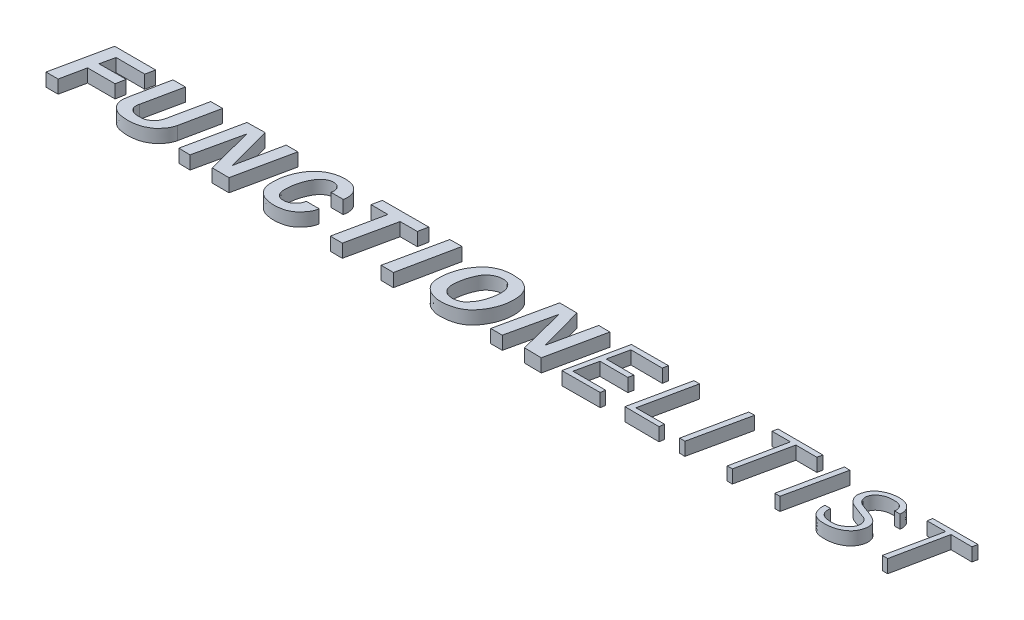
from build123d import *

# Parameters (mm, degrees)
BOSS_EXTRUDE1_DEPTH    = 25.4
BOSS_EXTRUDE1_2_DEPTH  = 25.4
BOSS_EXTRUDE1_3_DEPTH  = 25.4
BOSS_EXTRUDE1_4_DEPTH  = 25.4
BOSS_EXTRUDE1_5_DEPTH  = 25.4
BOSS_EXTRUDE1_6_DEPTH  = 25.4
BOSS_EXTRUDE1_7_DEPTH  = 25.4
BOSS_EXTRUDE1_8_DEPTH  = 25.4
BOSS_EXTRUDE1_9_DEPTH  = 25.4
BOSS_EXTRUDE1_10_DEPTH = 25.4
BOSS_EXTRUDE1_11_DEPTH = 25.4
BOSS_EXTRUDE1_12_DEPTH = 25.4
BOSS_EXTRUDE1_13_DEPTH = 25.4
BOSS_EXTRUDE1_14_DEPTH = 25.4
BOSS_EXTRUDE1_15_DEPTH = 25.4


with BuildPart() as part:
    # Sketch2 → Boss-Extrude1 (new body)
    with BuildSketch(Plane(origin=(0, 0, 0), x_dir=(1, 0, 0), z_dir=(0, 1, 0))):
        with BuildLine():
            add(Edge.make_bspline(
                [(1094.427173213, 172.997146135), (1091.367551701, 172.906654033), (1085.158357781, 172.889487077), (1076.817502855, 175.50371822), (1068.345517925, 178.404168185), (1061.504603762, 184.040645414), (1054.691032721, 192.448499642), (1052.102551889, 202.272409533), (1052.016567477, 212.151169643), (1052.188561023, 219.614340802), (1053.848126401, 228.614644219), (1056.261017051, 238.892210234), (1061.524966489, 251.84212287), (1068.453103531, 262.32447772), (1076.878332495, 272.415104771), (1085.877906637, 279.006460855), (1097.47703413, 284.33681498), (1108.098800253, 286.704500027), (1118.910320823, 287.395086765), (1128.310390006, 286.483917691), (1137.402240239, 285.679117248), (1144.816033322, 281.623384425), (1153.026267593, 275.767906793), (1158.262775228, 266.157317215), (1160.627021608, 255.642523502), (1161.153569292, 246.53633637), (1160.608373851, 237.02784107), (1158.723980019, 227.131158299), (1155.939995019, 218.091844341), (1151.872712965, 208.995350554), (1145.861238908, 198.526470413), (1137.37183718, 188.258938379), (1127.672033786, 181.13652136), (1119.963990562, 177.706508815), (1112.131167595, 175.264500154), (1103.861910343, 173.448851684), (1097.481943993, 173.087494771), (1094.427173213, 172.997146135)],
                knots=[0, 0, 0, 0, 0.025729682, 0.051931851, 0.073305152, 0.100820113, 0.125326139, 0.163809491, 0.183248995, 0.208899637, 0.226567481, 0.260387765, 0.297881818, 0.343867956, 0.365822433, 0.408624519, 0.436521725, 0.473173661, 0.49973853, 0.527560869, 0.553081825, 0.575613369, 0.59785567, 0.637572301, 0.663955073, 0.688711586, 0.714252853, 0.744180522, 0.773515788, 0.793866448, 0.828165547, 0.875213576, 0.905069137, 0.928882672, 0.946053606, 0.97431111, 1, 1, 1, 1], degree=3))
        make_face()
        with BuildLine():
            add(Edge.make_bspline(
                [(1098.369477116, 189.410559153), (1095.339913898, 189.726806675), (1089.506155554, 190.429641806), (1083.417050133, 193.896903849), (1080.724632289, 197.743942709), (1078.071870765, 201.356194307), (1076.633917417, 207.003621776), (1075.897203299, 214.974381959), (1077.513403819, 224.232305335), (1079.080110954, 234.174301375), (1082.37947845, 243.466317785), (1086.27753448, 252.729872997), (1092.195532664, 261.57819181), (1100.08218752, 266.558304181), (1107.922996096, 270.026920408), (1116.188907666, 270.926869451), (1125.301619767, 269.806230986), (1131.392204102, 264.299131948), (1135.086077048, 258.700627105), (1137.001086768, 252.391282942), (1137.069034285, 244.812539886), (1136.750024768, 235.251639968), (1133.98689045, 223.98986243), (1130.367111642, 213.1486423), (1124.624773393, 203.404718722), (1118.399178317, 196.717256904), (1113.593721508, 192.548947207), (1111.578933122, 191.848802187)],
                knots=[0, 0, 0, 0, 0.047623639, 0.07606652, 0.096690248, 0.113170499, 0.138968172, 0.177316361, 0.22569027, 0.270714363, 0.319285709, 0.364188653, 0.412774027, 0.466537936, 0.493207323, 0.533134683, 0.583074459, 0.616438865, 0.645306629, 0.677257278, 0.707725549, 0.751889888, 0.811960352, 0.870512297, 0.912744055, 0.970141319, 1, 1, 1, 1], degree=3))
            add(Edge.make_bspline(
                [(1098.369477116, 189.410559153), (1099.77902503, 189.263420439), (1105.610683136, 190.072330898), (1109.513215015, 191.130958937), (1111.578933122, 191.848802187)],
                knots=[0, 0, 0, 0, 0.517018761, 1, 1, 1, 1], degree=3))
        make_face(mode=Mode.SUBTRACT)
    extrude(amount=BOSS_EXTRUDE1_DEPTH)


with BuildPart() as body_2:
    # Sketch2 → Boss-Extrude1 2 (new body)
    with BuildSketch(Plane(origin=(0, 0, 0), x_dir=(1, 0, 0), z_dir=(0, 1, 0))):
        Polygon((330.211143627, 175.588495452), (353.316026943, 284.791417581), (432.439856311, 284.656163172), (428.787987263, 267.208344389), (373.46893391, 267.343598798), (367.517739906, 240.427971372), (419.590687439, 240.563225781), (416.344581619, 222.574389361), (363.324853222, 222.574389361), (353.557861827, 175.622714777), align=None)
    extrude(amount=BOSS_EXTRUDE1_2_DEPTH)


with BuildPart() as body_3:
    # Sketch2 → Boss-Extrude1 3 (new body)
    with BuildSketch(Plane(origin=(0, 0, 0), x_dir=(1, 0, 0), z_dir=(0, 1, 0))):
        with BuildLine():
            Line((465.540196151, 284.777155902), (450.797700158, 211.908410215))
            add(Edge.make_bspline(
                [(450.797700158, 211.908410215), (450.401697608, 209.951061263), (449.717545439, 204.157501389), (449.852392166, 197.959453274), (452.916704033, 189.162058328), (457.105550768, 184.239524107), (463.310862511, 178.887230238), (471.371299141, 175.382283828), (480.944030166, 174.219947151), (490.741843397, 173.364325457), (501.427717175, 174.468473393), (510.969600186, 176.46316405), (519.088167565, 180.128268969), (524.38190265, 183.416430797), (529.852703333, 186.567368504), (533.682775693, 191.213583721), (537.986958283, 195.989246419), (541.830788276, 201.489509829), (544.333106096, 207.38196973), (545.625201628, 211.201711691), (545.952916561, 212.778062002)],
                knots=[0, 0, 0, 0, 0.043908318, 0.110716089, 0.159392641, 0.219822207, 0.270449273, 0.330054706, 0.407839802, 0.477214937, 0.542146355, 0.63916272, 0.686233556, 0.733611926, 0.774060684, 0.821314961, 0.862079378, 0.913354099, 0.965139079, 1, 1, 1, 1], degree=3))
            Line((545.952916561, 212.778062002), (560.973854285, 285.030673838))
            Line((560.973854285, 285.030673838), (538.156978731, 284.984513081))
            Line((538.156978731, 284.984513081), (523.059522937, 212.98850838))
            add(Edge.make_bspline(
                [(474.104814663, 212.245925239), (473.820102179, 210.898651301), (473.341939715, 208.239660277), (473.391161168, 204.320719503), (473.872328244, 200.272471918), (476.172637579, 196.820507521), (479.426327198, 193.909333014), (483.996464702, 191.420527044), (490.181454969, 190.681063656), (497.056461391, 190.888433007), (503.5345067, 191.282569508), (508.939863463, 193.838388348), (513.258359653, 196.459428642), (516.953418015, 200.170161375), (519.81744566, 204.139227183), (521.924654749, 208.586712246), (522.742802557, 211.47814781), (523.059522937, 212.98850838)],
                knots=[0, 0, 0, 0, 0.055066425, 0.106590232, 0.156186474, 0.214690168, 0.266458337, 0.329688368, 0.418336241, 0.509803742, 0.605349791, 0.672337188, 0.745494903, 0.805585857, 0.879409694, 0.939580838, 1, 1, 1, 1], degree=3))
            Line((474.104814663, 212.245925239), (489.465951386, 284.935604612))
            Line((489.465951386, 284.935604612), (465.540196151, 284.777155902))
        make_face()
    extrude(amount=BOSS_EXTRUDE1_3_DEPTH)


with BuildPart() as body_4:
    # Sketch2 → Boss-Extrude1 4 (new body)
    with BuildSketch(Plane(origin=(0, 0, 0), x_dir=(1, 0, 0), z_dir=(0, 1, 0))):
        Polygon((585.218028048, 176.630460577), (607.888615981, 285.05501156), (642.387336748, 285.712130051), (665.715043172, 199.629607755), (683.457242424, 285.05501156), (705.943017035, 285.05501156), (682.635555628, 175.606991878), (650.172327201, 175.832430964), (626.952101312, 265.782626398), (607.113461717, 176.05787005), align=None)
    extrude(amount=BOSS_EXTRUDE1_4_DEPTH)


with BuildPart() as body_5:
    # Sketch2 → Boss-Extrude1 5 (new body)
    with BuildSketch(Plane(origin=(0, 0, 0), x_dir=(1, 0, 0), z_dir=(0, 1, 0))):
        with BuildLine():
            Line((796.528941351, 210.628773166), (821.363078455, 210.546812318))
            add(Edge.make_bspline(
                [(821.363078455, 210.546812318), (820.77586806, 205.084344469), (817.839684571, 198.332262823), (811.655602268, 190.447639529), (807.21814937, 185.342420577), (800.284432967, 180.05995394), (792.975181558, 176.082230005), (782.817673814, 174.009032956), (773.328021779, 172.58882257), (763.090067393, 173.529854994), (754.815944969, 175.210852365), (747.039980307, 178.257494428), (740.837431201, 183.420592228), (735.750465053, 189.811616705), (732.077539355, 199.629262376), (731.647655755, 212.18724466), (732.829275604, 225.694382033), (735.676598698, 236.095343852), (738.851822107, 245.197553714), (742.366016671, 252.237485189), (747.373116337, 260.721814049), (753.597255082, 267.548587626), (763.319959007, 276.65282138), (777.323695952, 283.194769785), (794.296815946, 286.298936908), (808.067949658, 284.769811956), (816.894555728, 281.225334283), (821.796806378, 276.928067532), (825.579463184, 272.689102131), (828.534772144, 267.303026755), (830.251032957, 259.4855433), (830.146607452, 253.307878925), (829.039741043, 249.395709479)],
                knots=[0, 0, 0, 0, 0.054999379, 0.072083259, 0.101177463, 0.122849587, 0.159869316, 0.183760308, 0.22711176, 0.256099158, 0.286962557, 0.312224743, 0.339401935, 0.367390346, 0.393755775, 0.443631789, 0.492575935, 0.530284588, 0.552055401, 0.589796325, 0.609451943, 0.651288915, 0.682398817, 0.743437002, 0.803855527, 0.854688806, 0.881272097, 0.898176147, 0.919988387, 0.938384456, 0.959446239, 1, 1, 1, 1], degree=3))
            Line((829.039741043, 249.395709479), (805.332899039, 249.395709479))
            add(Edge.make_bspline(
                [(796.528941351, 210.628773166), (796.136286957, 207.143896896), (794.317143157, 202.515966143), (789.847204333, 197.386058571), (786.193317877, 193.63919518), (780.215976284, 190.897113654), (773.273623453, 189.83302603), (765.80104898, 190.617660036), (760.06637365, 195.035277001), (756.050037195, 202.065995616), (755.978368859, 212.837420057), (757.032167583, 225.019535529), (760.349440305, 238.597129076), (765.052947191, 249.372676122), (770.597538656, 258.154387459), (776.40475905, 263.78689348), (783.241032826, 267.680480164), (789.985496621, 269.17248683), (795.619296807, 268.370210579), (800.023473378, 266.901536893), (805.762336688, 261.270620556), (806.796474701, 254.337681856), (805.332899039, 249.395709479)],
                knots=[0, 0, 0, 0, 0.063236051, 0.086131848, 0.122713905, 0.156521304, 0.202500897, 0.248775137, 0.287135484, 0.328458086, 0.390432241, 0.476348248, 0.550172603, 0.641096201, 0.687260725, 0.736691832, 0.785332173, 0.827671212, 0.858232345, 0.887348473, 0.90946641, 1, 1, 1, 1], degree=3))
        make_face()
    extrude(amount=BOSS_EXTRUDE1_5_DEPTH)


with BuildPart() as body_6:
    # Sketch2 → Boss-Extrude1 6 (new body)
    with BuildSketch(Plane(origin=(0, 0, 0), x_dir=(1, 0, 0), z_dir=(0, 1, 0))):
        Polygon((868.355863354, 285.51644482), (864.542540021, 267.453334295), (897.256840194, 267.252633067), (877.788821073, 175.732873072), (901.070163528, 175.532171844), (920.738883877, 267.252633067), (953.854586507, 267.252633067), (957.467208612, 285.717146048), align=None)
    extrude(amount=BOSS_EXTRUDE1_6_DEPTH)


with BuildPart() as body_7:
    # Sketch2 → Boss-Extrude1 7 (new body)
    with BuildSketch(Plane(origin=(0, 0, 0), x_dir=(1, 0, 0), z_dir=(0, 1, 0))):
        Polygon((998.610960364, 285.115042364), (1021.91365748, 285.313330907), (999.261651038, 175.718696665), (975.37420092, 176.086195898), align=None)
    extrude(amount=BOSS_EXTRUDE1_7_DEPTH)


with BuildPart() as body_8:
    # Sketch2 → Boss-Extrude1 8 (new body)
    with BuildSketch(Plane(origin=(0, 0, 0), x_dir=(1, 0, 0), z_dir=(0, 1, 0))):
        Polygon((1186.393844806, 176.107202506), (1208.712021212, 176.107202506), (1228.610154392, 265.648801819), (1251.197224489, 176.376096198), (1284.002254868, 175.838308814), (1307.114098655, 285.021708251), (1285.398730743, 285.195431194), (1266.726975925, 199.992290329), (1243.668201124, 285.009147616), (1210.05648967, 285.278041308), align=None)
    extrude(amount=BOSS_EXTRUDE1_8_DEPTH)


with BuildPart() as body_9:
    # Sketch2 → Boss-Extrude1 9 (new body)
    with BuildSketch(Plane(origin=(0, 0, 0), x_dir=(1, 0, 0), z_dir=(0, 1, 0))):
        Polygon((1348.600046157, 285.021708251), (1325.179330807, 174.430099376), (1398.671920352, 174.833904813), (1400.085239382, 183.919527147), (1336.889688482, 183.919527147), (1346.379116253, 226.722903475), (1400.085239382, 226.521000757), (1402.104266567, 236.212331246), (1348.600046157, 236.414233965), (1357.079960335, 275.583361359), (1417.852678612, 275.179555922), (1419.669803079, 285.274691849), align=None)
    extrude(amount=BOSS_EXTRUDE1_9_DEPTH)


with BuildPart() as body_10:
    # Sketch2 → Boss-Extrude1 10 (new body)
    with BuildSketch(Plane(origin=(0, 0, 0), x_dir=(1, 0, 0), z_dir=(0, 1, 0))):
        Polygon((1469.169264104, 284.723396042), (1479.998179169, 285.008367491), (1458.625320488, 183.558531621), (1513.624810159, 183.84350307), (1512.199952914, 174.43944525), (1446.086576729, 175.009388148), align=None)
    extrude(amount=BOSS_EXTRUDE1_10_DEPTH)


with BuildPart() as body_11:
    # Sketch2 → Boss-Extrude1 11 (new body)
    with BuildSketch(Plane(origin=(0, 0, 0), x_dir=(1, 0, 0), z_dir=(0, 1, 0))):
        Polygon((1574.323728812, 285.29333894), (1585.437615326, 285.578310389), (1561.500013604, 175.009388148), (1551.241041437, 175.294359598), align=None)
    extrude(amount=BOSS_EXTRUDE1_11_DEPTH)


with BuildPart() as body_12:
    # Sketch2 → Boss-Extrude1 12 (new body)
    with BuildSketch(Plane(origin=(0, 0, 0), x_dir=(1, 0, 0), z_dir=(0, 1, 0))):
        Polygon((1630.830979126, 285.23426299), (1628.906761327, 275.613173993), (1664.312368836, 275.613173993), (1643.530816602, 174.591739523), (1653.344327379, 174.591739523), (1674.895566733, 275.613173993), (1715.304140521, 275.420752213), (1717.4207801, 285.04184121), align=None)
    extrude(amount=BOSS_EXTRUDE1_12_DEPTH)


with BuildPart() as body_13:
    # Sketch2 → Boss-Extrude1 13 (new body)
    with BuildSketch(Plane(origin=(0, 0, 0), x_dir=(1, 0, 0), z_dir=(0, 1, 0))):
        Polygon((1758.214197448, 285.81152833), (1768.797395345, 285.42668477), (1744.937094632, 174.591739523), (1734.931162075, 174.784161303), align=None)
    extrude(amount=BOSS_EXTRUDE1_13_DEPTH)


with BuildPart() as body_14:
    # Sketch2 → Boss-Extrude1 14 (new body)
    with BuildSketch(Plane(origin=(0, 0, 0), x_dir=(1, 0, 0), z_dir=(0, 1, 0))):
        with BuildLine():
            Line((1803.348911441, 203.145145396), (1814.387704917, 203.145145396))
            add(Edge.make_bspline(
                [(1814.387704917, 203.145145396), (1813.602581361, 199.314391064), (1813.52385818, 192.580839472), (1818.998224637, 185.049847075), (1826.969218866, 181.933629152), (1836.658131859, 180.737735589), (1847.95121345, 181.373629082), (1858.212213382, 186.980902149), (1866.802565726, 194.73281839), (1870.786272468, 206.25916105), (1865.901705673, 219.014938237), (1853.360171342, 222.27686775), (1843.273633472, 226.096121538), (1834.75486838, 229.592553441), (1827.475429508, 232.784444458), (1821.430312252, 239.082113584), (1816.042089298, 247.804196863), (1818.087656124, 258.864246969), (1821.818987071, 268.897137437), (1828.81787057, 276.695561225), (1837.804969595, 282.030127082), (1847.738494466, 285.877965512), (1859.216479357, 287.468380645), (1871.21488531, 287.152120533), (1882.391951772, 282.77622764), (1889.922716966, 272.998911098), (1890.998681284, 265.018801795), (1890.287069698, 260.759954265)],
                knots=[0, 0, 0, 0, 0.044977098, 0.071795646, 0.100100846, 0.139122413, 0.182783947, 0.225458352, 0.269246472, 0.311511383, 0.356589328, 0.405222061, 0.448856381, 0.480891809, 0.509755989, 0.537718812, 0.579265104, 0.619544986, 0.659199969, 0.700614137, 0.735020236, 0.777218611, 0.820574001, 0.865624523, 0.912641063, 0.951111499, 1, 1, 1, 1], degree=3))
            Line((1890.287069698, 260.759954265), (1879.49787661, 260.771389307))
            add(Edge.make_bspline(
                [(1803.348911441, 203.145145396), (1802.629169476, 198.421799771), (1803.680995018, 190.785094471), (1807.577718622, 180.896856241), (1814.008715519, 175.653234436), (1821.663643117, 172.327783988), (1831.339824749, 171.835972162), (1844.456492391, 172.101717658), (1859.48444563, 176.460738323), (1873.18905772, 185.987179298), (1879.63295825, 198.338554164), (1881.584675639, 209.696851817), (1879.128827915, 220.724768416), (1869.003750725, 228.660357249), (1856.100439282, 233.391324192), (1843.577153874, 237.556270249), (1832.690807875, 242.845921115), (1828.275974857, 251.955699358), (1828.902353677, 261.214717487), (1833.967862022, 268.71040014), (1841.172805362, 273.72616038), (1849.544808166, 277.273678085), (1858.477616205, 277.873846411), (1866.758518824, 277.937893364), (1873.354810262, 276.215840801), (1879.434872221, 270.826230311), (1880.816056986, 264.632310408), (1879.49787661, 260.771389307)],
                knots=[0, 0, 0, 0, 0.053084905, 0.086629098, 0.116684798, 0.143953255, 0.179636199, 0.22461318, 0.291952427, 0.353161957, 0.407420651, 0.444037636, 0.482182102, 0.528075717, 0.581277424, 0.637462307, 0.678446451, 0.712599484, 0.744697149, 0.778971898, 0.810628424, 0.842932715, 0.880225203, 0.910512297, 0.936616019, 0.954688172, 1, 1, 1, 1], degree=3))
        make_face()
    extrude(amount=BOSS_EXTRUDE1_14_DEPTH)


with BuildPart() as body_15:
    # Sketch2 → Boss-Extrude1 15 (new body)
    with BuildSketch(Plane(origin=(0, 0, 0), x_dir=(1, 0, 0), z_dir=(0, 1, 0))):
        Polygon((1929.083046936, 284.857272609), (1927.704461026, 275.457823221), (1963.547694691, 275.583149213), (1942.213655417, 174.681290803), (1952.616408182, 174.536808126), (1973.46533871, 275.698113462), (2014.125194711, 275.32959513), (2016.090625817, 285.156750659), align=None)
    extrude(amount=BOSS_EXTRUDE1_15_DEPTH)


solid = Compound([part.part, body_2.part, body_3.part, body_4.part, body_5.part, body_6.part, body_7.part, body_8.part, body_9.part, body_10.part, body_11.part, body_12.part, body_13.part, body_14.part, body_15.part])
